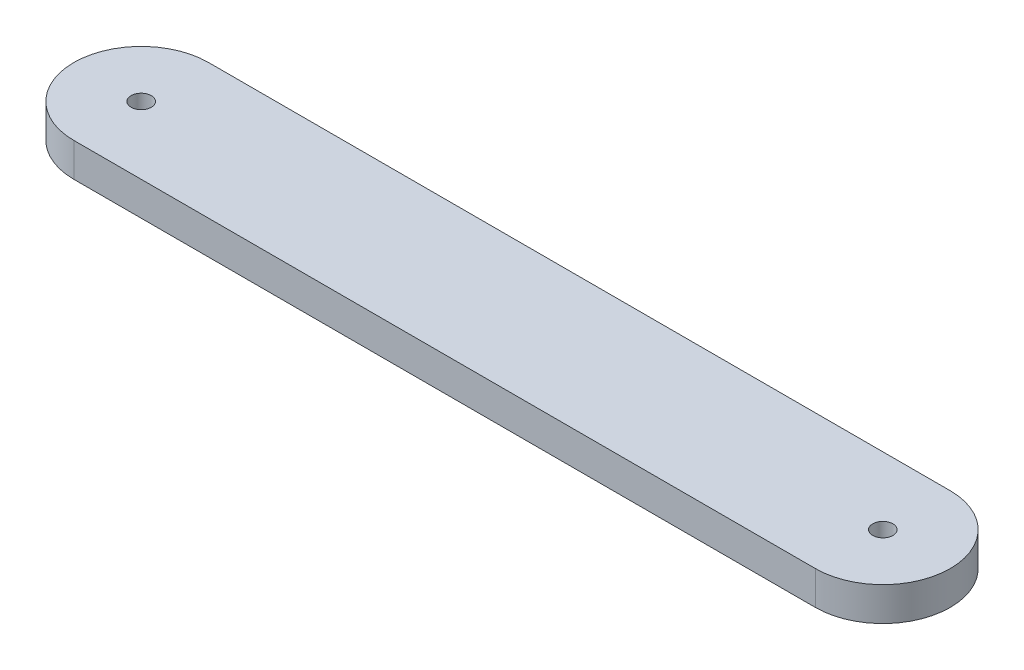
from build123d import *

# Parameters (mm, degrees)
SKETCH1_R           = 3
BOSS_EXTRUDE1_DEPTH = 10


with BuildPart() as part:
    # Sketch1 → Boss-Extrude1 (new body)
    with BuildSketch(Plane(origin=(0, 0, 0), x_dir=(1, 0, 0), z_dir=(0, 1, 0))):
        with BuildLine():
            Line((220, 20), (0, 20))
            ThreePointArc((0, 20), (-20, 0), (0, -20))
            Line((0, -20), (220, -20))
            ThreePointArc((220, -20), (240, 0), (220, 20))
        make_face()
        Circle(SKETCH1_R, mode=Mode.SUBTRACT)
        with Locations((220, 0)):
            Circle(SKETCH1_R, mode=Mode.SUBTRACT)
    extrude(amount=BOSS_EXTRUDE1_DEPTH)


solid = part.part
